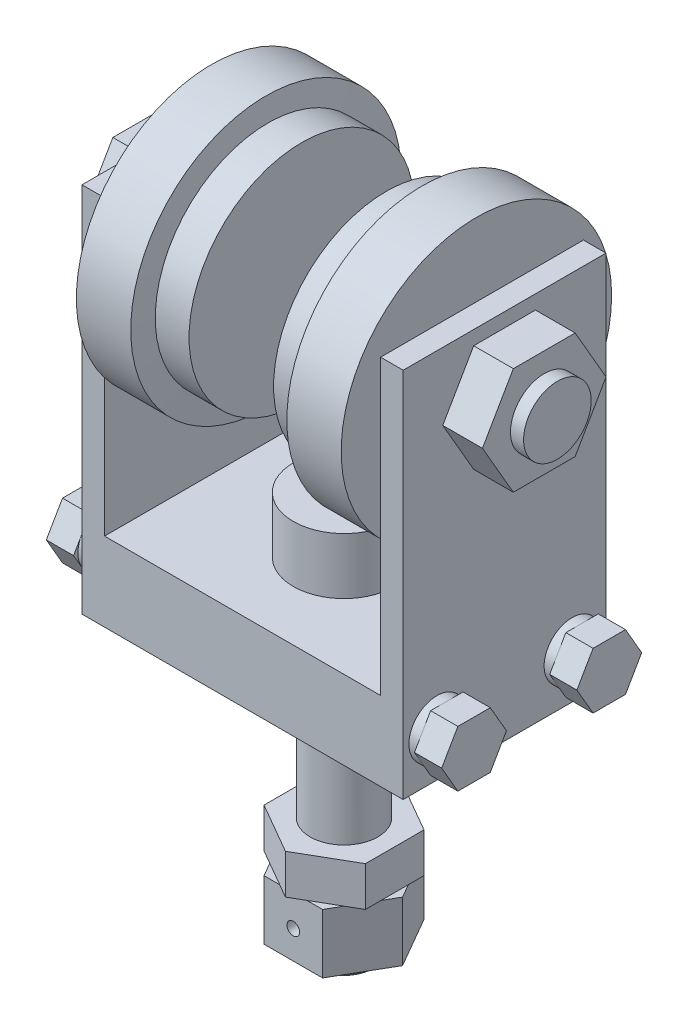
from build123d import *

# Parameters (mm, degrees)
YOKE_CROSS_SECTION_W           = 114.3
YOKE_CROSS_SECTION_H           = 44.45
YOKE_DEPTH                     = 77.7875
SIDEPLATE_PROFILE_W            = 114.3
SIDEPLATE_PROFILE_H            = 209.55
SIDEPLATE_DEPTH                = 12.7
WHEEL_PIN_NUT_DEPTH            = 22.352
WHEEL_PIN_PROJECTION_PROFILE_R = 19.05
WHEEL_PIN_PROJECTION_DEPTH     = 7.4168
LOCKNUTS_PROFILE_R             = 15.8115
LOCKNUTS_DEPTH                 = 5.5626
SCREWS_DEPTH                   = 15.3416
PROFILE_R                      = 28.575
KING_BOLT_HEAD_DEPTH           = 31.75
DIA_R                          = 19.05
KING_BOLT_DEPTH                = 82.55
KING_BOLT_JAM_NUT_DEPTH        = 22.352
KING_BOLT_NUT_DEPTH            = 33.4518
SKETCH5_R                      = 19.05
EXTENDED_KING_BOLT_DEPTH       = 9.525
CHAMFER1_SIZE                  = 2.38125
COTTER_PIN_HOLE_REACH          = 106.775
SKETCH7_R                      = 3.571875


with BuildPart() as part:
    # YOKE CROSS SECTION → YOKE (new body)
    with BuildSketch(Plane(origin=(0, 0, 0), x_dir=(0, 0, -1), z_dir=(1, 0, 0))):
        with Locations((0, 22.225)):
            Rectangle(YOKE_CROSS_SECTION_W, YOKE_CROSS_SECTION_H)
    extrude(amount=YOKE_DEPTH)

    # SIDEPLATE PROFILE → SIDEPLATE (add)
    with BuildSketch(Plane(origin=(77.7875, 0, 0), x_dir=(0, 0, -1), z_dir=(1, 0, 0))):
        with Locations((0, 104.775)):
            Rectangle(SIDEPLATE_PROFILE_W, SIDEPLATE_PROFILE_H)
    extrude(amount=SIDEPLATE_DEPTH)

    # WHEEL PIN NUT PROFILE → WHEEL PIN NUT (add)
    with BuildSketch(Plane(origin=(90.4875, 0, 0), x_dir=(0, 0, -1), z_dir=(1, 0, 0))):
        Polygon((34.828654989, 171.45), (17.414327494, 201.6125), (-17.414327494, 201.6125), (-34.828654989, 171.45), (-17.414327494, 141.2875), (17.414327494, 141.2875), align=None)
    extrude(amount=WHEEL_PIN_NUT_DEPTH)

    # WHEEL PIN PROJECTION PROFILE → WHEEL PIN PROJECTION (add)
    with BuildSketch(Plane(origin=(112.8395, 0, 0), x_dir=(0, 0, -1), z_dir=(1, 0, 0))):
        with Locations((0, 171.45)):
            Circle(WHEEL_PIN_PROJECTION_PROFILE_R)
    extrude(amount=WHEEL_PIN_PROJECTION_DEPTH)

    # LOCKNUTS PROFILE → LOCKNUTS (add)
    with BuildSketch(Plane(origin=(90.4875, 0, 0), x_dir=(0, 0, -1), z_dir=(1, 0, 0))):
        with Locations((-38.1, 25.4)):
            Circle(LOCKNUTS_PROFILE_R)
    locknuts = extrude(amount=LOCKNUTS_DEPTH)

    # SCREWS PROFILE → SCREWS (add)
    with BuildSketch(Plane(origin=(96.0501, 0, 0), x_dir=(0, 0, -1), z_dir=(1, 0, 0))):
        Polygon((-19.842452437, 25.4), (-28.971226219, 41.2115), (-47.228773781, 41.2115), (-56.357547563, 25.4), (-47.228773781, 9.5885), (-28.971226219, 9.5885), align=None)
    screws = extrude(amount=SCREWS_DEPTH)

    # PROFILE → KING BOLT HEAD (add)
    with BuildSketch(Plane(origin=(0, 44.45, 0), x_dir=(-1, 0, 0), z_dir=(0, 1, 0))):
        with Locations(Location((0, 0, 0), (0, 0, 90))):  # turned: the seam where the file's is
            Circle(PROFILE_R)
    extrude(amount=KING_BOLT_HEAD_DEPTH)

    # Mirror1: LOCKNUTS, SCREWS across plane
    add(locknuts.mirror(Plane.XY))
    add(screws.mirror(Plane.XY))

    # Mirror5: part across plane


with BuildPart() as part_1:
    add(part.part)
    add(part.part.mirror(Plane(origin=(0, 0, 0), x_dir=(0, 0, 1), z_dir=(1, 0, 0))))

    # DIA. → KING BOLT (add)
    with BuildSketch(Plane.XZ):
        with Locations(Location((0, 0, 0), (0, 0, 90))):  # turned: the seam where the file's is
            Circle(DIA_R)
    extrude(amount=KING_BOLT_DEPTH)

    # KING BOLT JAN NUT PROFILE → KING BOLT JAM NUT (add)
    with BuildSketch(Plane.XZ.offset(82.55)):
        Polygon((0, -32.995567884), (28.575, -16.497783942), (28.575, 16.497783942), (0, 32.995567884), (-28.575, 16.497783942), (-28.575, -16.497783942), align=None)
    extrude(amount=KING_BOLT_JAM_NUT_DEPTH)

    # KING BOLT NUT PROFILE → KING BOLT NUT (add)
    with BuildSketch(Plane.XZ.offset(104.902)):
        Polygon((32.995567884, 0), (16.497783942, 28.575), (-16.497783942, 28.575), (-32.995567884, 0), (-16.497783942, -28.575), (16.497783942, -28.575), align=None)
    extrude(amount=KING_BOLT_NUT_DEPTH)

    # Sketch5 → EXTENDED KING BOLT (add)
    with BuildSketch(Plane.XZ.offset(138.3538)):
        with Locations(Location((0, 0, 0), (0, 0, 90))):  # turned: the seam where the file's is
            Circle(SKETCH5_R)
    extrude(amount=EXTENDED_KING_BOLT_DEPTH)

    # Chamfer1
    chamfer1_edges = [part_1.edges().sort_by_distance(p)[0] for p in [
        (0, -147.8788, -19.05),
    ]]
    chamfer(chamfer1_edges, length=CHAMFER1_SIZE)

    # Sketch6 → WHEEL (revolve)
    with BuildSketch(Plane.XY, mode=Mode.PRIVATE) as wheel_sk:
        Polygon((43.973606027, 247.65), (42.8625, 234.95), (23.8125, 234.95), (23.8125, 171.45), (77.7875, 171.45), (77.7875, 198.084794967), (74.6125, 198.084794967), (74.6125, 247.65), align=None)
    wheel = revolve(wheel_sk.sketch.rotate(Axis((120.2563, 171.45, 0), (-1, 0, 0)), 90), axis=Axis((120.2563, 171.45, 0), (-1, 0, 0)))  # turned: the seam where the file's is

    # Mirror6: WHEEL across plane
    add(wheel.mirror(Plane(origin=(0, 0, 0), x_dir=(0, 0, 1), z_dir=(1, 0, 0))))

    # Sketch7 → COTTER PIN HOLE (cut, up to next)
    with BuildSketch(Plane.XY.offset(28.575), mode=Mode.PRIVATE) as cotter_pin_hole_sk1:
        with Locations((0, -122.4788)):
            Circle(SKETCH7_R)
    cotter_pin_hole_tool1 = extrude(cotter_pin_hole_sk1.sketch, amount=-COTTER_PIN_HOLE_REACH, mode=Mode.PRIVATE) & part_1.part
    add(cotter_pin_hole_tool1.solids().sort_by_distance((0, -122.4788, 28.575))[0], mode=Mode.SUBTRACT)


solid = part_1.part
